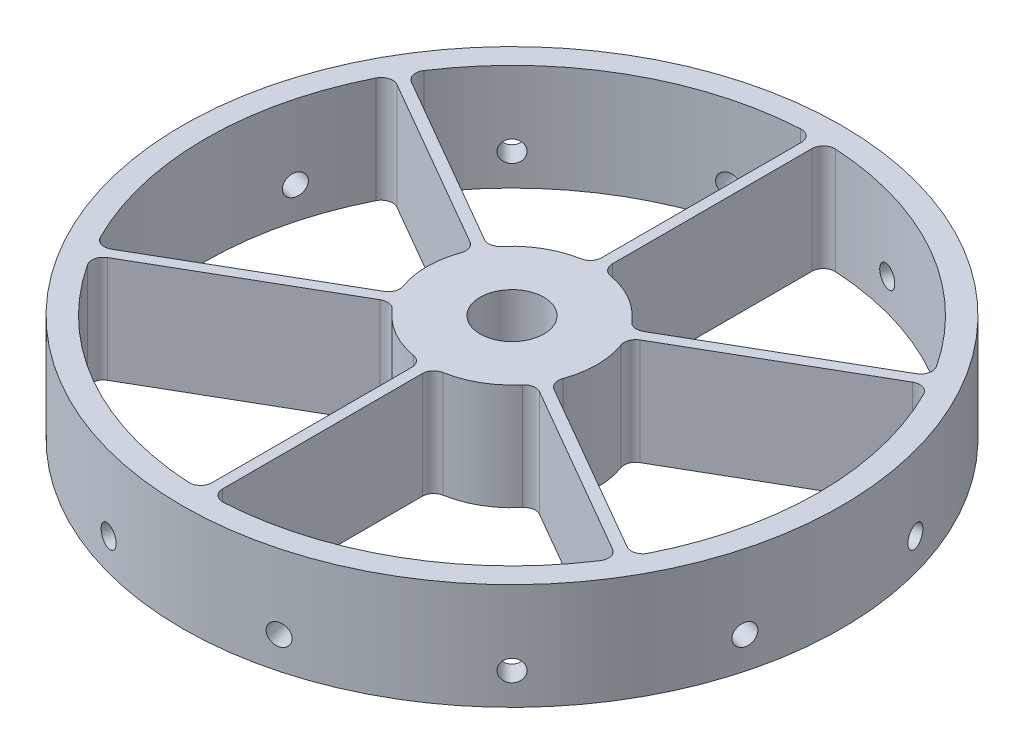
from build123d import *

# Parameters (mm, degrees)
RING_R                = 25.4
BOSS_EXTRUDE1_DEPTH   = 15.875
RING_R_2              = 98.425
RING_R_3              = 91.567
BOSS_EXTRUDE1_2_DEPTH = 15.875
BOSS_EXTRUDE2_DEPTH   = 15.875
CIRPATTERN1_COUNT     = 6
FILLET1_R             = 3.429
SKETCH8_R             = 9.525
CUT_EXTRUDE1_DEPTH    = 143.76912744
CUT_EXTRUDE2_START    = 38.1
SKETCH10_R            = 3.175
CUT_EXTRUDE2_DEPTH    = 102.996312853
CIRPATTERN3_COUNT     = 12


with BuildPart() as part:
    # ring → Boss-Extrude1 (new, symmetric)
    with BuildSketch(Plane(origin=(0, 0, 0), x_dir=(1, 0, 0), z_dir=(0, 1, 0))):
        Circle(RING_R)
    extrude(amount=BOSS_EXTRUDE1_DEPTH, both=True)



with BuildPart() as body_2:
    # ring → Boss-Extrude1 2 (new, symmetric)
    with BuildSketch(Plane(origin=(0, 0, 0), x_dir=(1, 0, 0), z_dir=(0, 1, 0))):
        Circle(RING_R_2)
        Circle(RING_R_3, mode=Mode.SUBTRACT)
    extrude(amount=BOSS_EXTRUDE1_2_DEPTH, both=True)


with BuildPart() as part_1:
    add(part.part)

    add(body_2.part)  # Boss-Extrude2 merges body 2
    # beam → Boss-Extrude2 (add, symmetric)
    with BuildSketch(Plane(origin=(0, 0, 0), x_dir=(1, 0, 0), z_dir=(0, 1, 0))):
        with BuildLine():
            Line((1.5875, 25.350342083), (1.5875, 97.777113599))
            ThreePointArc((1.5875, 97.777113599), (0, 97.79), (-1.5875, 97.777113599))
            Line((-1.5875, 97.777113599), (-1.5875, 25.350342083))
            ThreePointArc((-1.5875, 25.350342083), (0, 25.4), (1.5875, 25.350342083))
        make_face()
    boss_extrude2 = extrude(amount=BOSS_EXTRUDE2_DEPTH, both=True)

    # CirPattern1: Boss-Extrude2 ×6 about axis
    cirpattern1_axis = Axis((0, 21.835457169, 0), (0, -1, 0))
    for i in range(1, CIRPATTERN1_COUNT):
        add(boss_extrude2.rotate(cirpattern1_axis, i * 360 / CIRPATTERN1_COUNT))

    # Fillet1
    fillet1_edges = [part_1.edges().sort_by_distance(p)[0] for p in [
        (-80.081179644, 0, 44.40180352),
        (-80.081179644, 0, -44.40180352),
        (-22.747790239, 0, 11.300355713),
        (-22.747790239, 0, -11.300355713),
        (-21.160290239, 0, -14.04998637),
        (-1.5875, 0, -25.350342083),
        (-78.493679644, 0, -47.151434177),
        (-1.5875, 0, -91.553237697),
        (1.5875, 0, -91.553237697),
        (78.493679644, 0, -47.151434177),
        (21.160290239, 0, -14.04998637),
        (1.5875, 0, -25.350342083),
        (22.747790239, 0, 11.300355713),
        (22.747790239, 0, -11.300355713),
        (80.081179644, 0, 44.40180352),
        (80.081179644, 0, -44.40180352),
        (1.5875, 0, 91.553237697),
        (1.5875, 0, 25.350342083),
        (21.160290239, 0, 14.04998637),
        (78.493679644, 0, 47.151434177),
        (-1.5875, 0, 91.553237697),
        (-1.5875, 0, 25.350342083),
        (-21.160290239, 0, 14.04998637),
        (-78.493679644, 0, 47.151434177),
    ]]
    fillet(fillet1_edges, radius=FILLET1_R)

    # Sketch8 → Cut-Extrude1 (cut, through all)
    with BuildSketch(Plane(origin=(0, 15.875, 0), x_dir=(1, 0, 0), z_dir=(0, 1, 0))):
        Circle(SKETCH8_R)
    extrude(amount=-CUT_EXTRUDE1_DEPTH, mode=Mode.SUBTRACT)

    # Sketch10 → Cut-Extrude2 (cut, through all)
    with BuildSketch(Plane(origin=(0, 0, 0), x_dir=(0, -1, 0), z_dir=(-0.25881904510251796, 0, -0.9659258262890691)).offset(CUT_EXTRUDE2_START)):
        with Locations((19.05, 0)):
            Circle(SKETCH10_R)
        with Locations((6.35, 0)):
            Circle(SKETCH10_R)
    cut_extrude2 = extrude(amount=CUT_EXTRUDE2_DEPTH, mode=Mode.SUBTRACT)

    # CirPattern3: Cut-Extrude2 ×12 about axis
    cirpattern3_axis = Axis((0, 15.875, 0), (0, -1, 0))
    for i in range(1, CIRPATTERN3_COUNT):
        add(cut_extrude2.rotate(cirpattern3_axis, i * 360 / CIRPATTERN3_COUNT), mode=Mode.SUBTRACT)


solid = part_1.part
